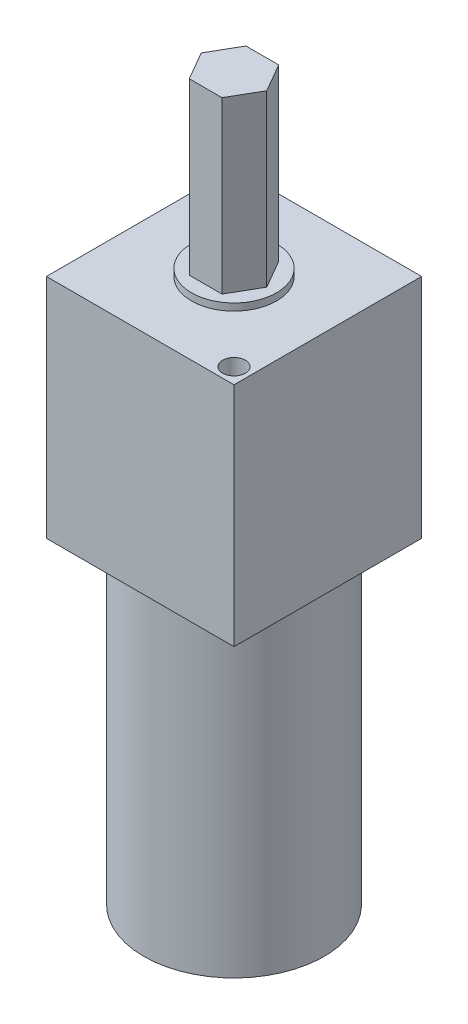
from build123d import *

# Parameters (mm, degrees)
SKETCH1_W           = 42.0116
SKETCH1_H           = 42.0116
SKETCH1_R           = 2.54
BOSS_EXTRUDE1_DEPTH = 50.8
SKETCH2_R           = 9.525
BOSS_EXTRUDE2_DEPTH = 1.5875
BOSS_EXTRUDE3_DEPTH = 38.1
SKETCH4_R           = 20.193
BOSS_EXTRUDE4_DEPTH = 70.993


with BuildPart() as part:
    # Sketch1 → Boss-Extrude1 (new body)
    with BuildSketch(Plane(origin=(0, 0, 0), x_dir=(1, 0, 0), z_dir=(0, 1, 0))):
        Rectangle(SKETCH1_W, SKETCH1_H)
        with Locations((-17.50251918, 17.50251918)):
            Circle(SKETCH1_R, mode=Mode.SUBTRACT)
        with Locations((17.50251918, -17.50251918)):
            Circle(SKETCH1_R, mode=Mode.SUBTRACT)
    extrude(amount=BOSS_EXTRUDE1_DEPTH)

    # Sketch2 → Boss-Extrude2 (add)
    with BuildSketch(Plane(origin=(0, 50.8, 0), x_dir=(1, 0, 0), z_dir=(0, 1, 0))):
        Circle(SKETCH2_R)
    extrude(amount=BOSS_EXTRUDE2_DEPTH)

    # Sketch3 → Boss-Extrude3 (add)
    with BuildSketch(Plane(origin=(0, 52.3875, 0), x_dir=(1, 0, 0), z_dir=(0, 1, 0))):
        Polygon((3.666174209, -6.35), (7.332348419, 0), (3.666174209, 6.35), (-3.666174209, 6.35), (-7.332348419, 0), (-3.666174209, -6.35), align=None)
    extrude(amount=BOSS_EXTRUDE3_DEPTH)

    # Sketch4 → Boss-Extrude4 (add)
    with BuildSketch(Plane.XZ):
        Circle(SKETCH4_R)
    extrude(amount=BOSS_EXTRUDE4_DEPTH)


solid = part.part
